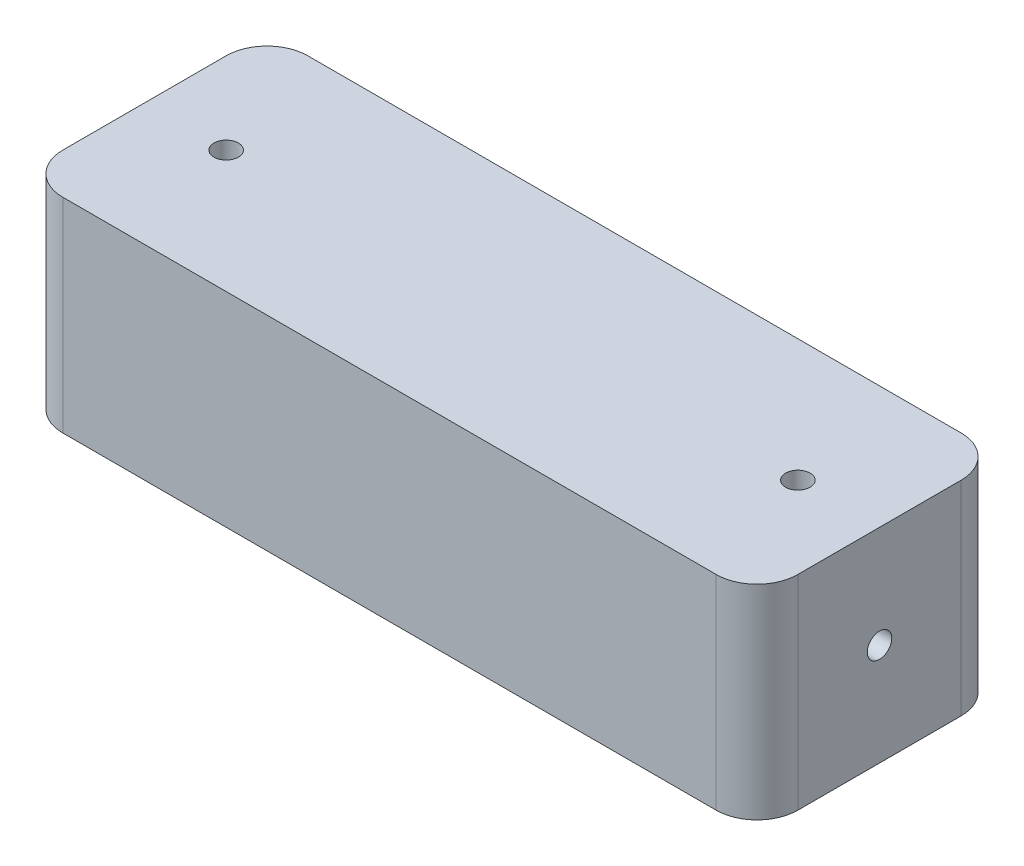
from build123d import *

# Parameters (mm, degrees)
SKETCH1_W           = 180
SKETCH1_H           = 60
SKETCH1_R           = 3
BOSS_EXTRUDE1_DEPTH = 50
SKETCH2_R           = 3
CUT_EXTRUDE1_DEPTH  = 10
FILLET1_R           = 10


with BuildPart() as part:
    # Sketch1 → Boss-Extrude1 (new body)
    with BuildSketch(Plane(origin=(0, 0, 0), x_dir=(1, 0, 0), z_dir=(0, 1, 0))):
        with Locations((90, 30)):
            Rectangle(SKETCH1_W, SKETCH1_H)
        with Locations((20, 30)):
            Circle(SKETCH1_R, mode=Mode.SUBTRACT)
        with Locations((160, 30)):
            Circle(SKETCH1_R, mode=Mode.SUBTRACT)
    extrude(amount=BOSS_EXTRUDE1_DEPTH)

    # Sketch2 → Cut-Extrude1 (cut)
    with BuildSketch(Plane(origin=(180, 0, 0), x_dir=(0, 0, -1), z_dir=(1, 0, 0))):
        with Locations((30, 25)):
            Circle(SKETCH2_R)
    extrude(amount=-CUT_EXTRUDE1_DEPTH, mode=Mode.SUBTRACT)

    # Fillet1
    fillet1_edges = [part.edges().sort_by_distance(p)[0] for p in [
        (0, 25, -60),
        (180, 25, -60),
        (180, 25, 0),
        (0, 25, 0),
    ]]
    fillet(fillet1_edges, radius=FILLET1_R)


solid = part.part
